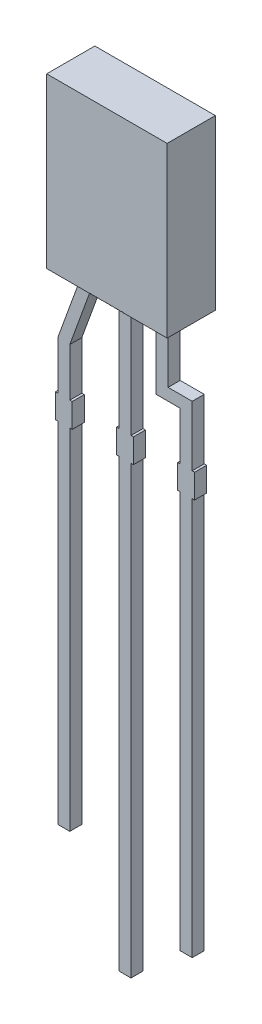
from build123d import *

# Parameters (mm, degrees)
EXTRUDE1_DEPTH     = 1
EXTRUDE2_DEPTH     = 0.25
SKETCH4_W          = 0.025316456
SKETCH4_H          = 0.026582278
CUT_EXTRUDE1_DEPTH = 0.01


with BuildPart() as part:
    # Sketch3 → Extrude1 (new body, symmetric)
    with BuildSketch(Plane(origin=(0, 0, 0), x_dir=(-1, 0, 0), z_dir=(0, 0, -1))):
        Polygon((-2.5, 0), (-1.79, 0), (-1.29, 0), (-0.25, 0), (0.25, 0), (1.198089297, 0), (1.698089297, 0), (2.5, 0), (2.5, 7), (-2.5, 7), align=None)
    extrude(amount=EXTRUDE1_DEPTH, both=True)

    # Sketch3_4 → Extrude2 (add, symmetric)
    with BuildSketch(Plane(origin=(0, 0, 0), x_dir=(-1, 0, 0), z_dir=(0, 0, -1))):
        Polygon((-1.29, 0), (-1.79, 0), (-1.79, -2.5), (-2.79, -2.5), (-2.79, -5), (-2.89, -5), (-2.89, -6), (-2.79, -6), (-2.79, -22.5), (-2.29, -22.5), (-2.29, -6), (-2.19, -6), (-2.19, -5), (-2.29, -5), (-2.29, -3), (-1.29, -3), align=None)
        Polygon((0.25, 0), (-0.25, 0), (-0.25, -5), (-0.35, -5), (-0.35, -6), (-0.25, -6), (-0.25, -24.5), (0.25, -24.5), (0.25, -6), (0.35, -6), (0.35, -5), (0.25, -5), align=None)
        Polygon((1.698089297, 0), (1.198089297, 0), (2.29, -3), (2.29, -5), (2.19, -5), (2.19, -6), (2.29, -6), (2.29, -20.5), (2.79, -20.5), (2.79, -6), (2.89, -6), (2.89, -5), (2.79, -5), (2.79, -3), align=None)
    extrude(amount=EXTRUDE2_DEPTH, both=True)

    # Sketch4 → Cut-Extrude1 (cut)
    with BuildSketch(Plane.XZ):
        Polygon((0.572151899, 0.925316456), (0.595609177, 1), (0.620352057, 1), (0.636768196, 0.949663766), (0.652294304, 1), (0.678026108, 1), (0.701265823, 0.925316456), (0.676087816, 0.925316456), (0.663093354, 0.976799842), (0.646677215, 0.925316456), (0.625178006, 0.925316456), (0.608860759, 0.976799842), (0.596044304, 0.925316456), align=None)
        Polygon((0.437974684, 0.925316456), (0.461431962, 1), (0.486174842, 1), (0.502590981, 0.949663766), (0.518117089, 1), (0.543848892, 1), (0.567088608, 0.925316456), (0.541910601, 0.925316456), (0.528916139, 0.976799842), (0.5125, 0.925316456), (0.491000791, 0.925316456), (0.474683544, 0.976799842), (0.461867089, 0.925316456), align=None)
        Polygon((0.303797468, 0.925316456), (0.327254747, 1), (0.351997627, 1), (0.368413766, 0.949663766), (0.383939873, 1), (0.409671677, 1), (0.432911392, 0.925316456), (0.407733386, 0.925316456), (0.394738924, 0.976799842), (0.378322785, 0.925316456), (0.356823576, 0.925316456), (0.340506329, 0.976799842), (0.327689873, 0.925316456), align=None)
        with Locations((0.275949367, 0.986708861)):
            Rectangle(SKETCH4_W, SKETCH4_H)
        with BuildLine():
            add(Edge.make_bspline(
                [(0.159493671, 0.968829114), (0.159530199, 0.970051228), (0.159601928, 0.972451052), (0.16021109, 0.975959018), (0.161206614, 0.979282301), (0.162570953, 0.982445017), (0.164384941, 0.985400383), (0.166539954, 0.98821895), (0.169151869, 0.990802912), (0.172088905, 0.993241673), (0.175386832, 0.995424068), (0.178989454, 0.997324206), (0.182859774, 0.998948925), (0.187013794, 1.000280615), (0.191459372, 1.001271382), (0.196177149, 1.001994699), (0.201170497, 1.002468207), (0.204594085, 1.002510148), (0.206348892, 1.002531646)],
                knots=[0, 0, 0, 0, 0.907421153, 1.781872267, 2.635683434, 3.480115191, 4.332689235, 5.205575272, 6.109500117, 7.055808355, 8.037942167, 9.041423561, 10.07750834, 11.152467461, 12.277657752, 13.45734338, 14.696726425, 16, 16, 16, 16], degree=3))
            add(Edge.make_bspline(
                [(0.206348892, 1.002531646), (0.208366877, 1.002504381), (0.212275063, 1.002451577), (0.217942631, 1.002066204), (0.223206098, 1.001378254), (0.228103845, 1.000421674), (0.232708145, 0.999218389), (0.23714149, 0.997927745), (0.241422782, 0.996463164), (0.244195874, 0.995363028), (0.24556962, 0.994818038)],
                knots=[0, 0, 0, 0, 1.203182053, 2.33017619, 3.384818652, 4.366208123, 5.30340534, 6.221361684, 7.118890722, 8, 8, 8, 8], degree=3))
            Line((0.24556962, 0.994818038), (0.24556962, 0.970886076))
            Line((0.24556962, 0.970886076), (0.242721519, 0.970886076))
            add(Edge.make_bspline(
                [(0.242721519, 0.970886076), (0.241355956, 0.971967039), (0.238632846, 0.974122618), (0.234205888, 0.976890972), (0.229546876, 0.979263982), (0.224708482, 0.981246605), (0.219807114, 0.982822219), (0.214938046, 0.983949125), (0.210169064, 0.984688489), (0.207010742, 0.98477005), (0.205458861, 0.984810127)],
                knots=[0, 0, 0, 0, 1.030738938, 2.055426519, 3.085610749, 4.123842265, 5.148648843, 6.130724483, 7.081507926, 8, 8, 8, 8], degree=3))
            add(Edge.make_bspline(
                [(0.205458861, 0.984810127), (0.205030115, 0.984808826), (0.204112202, 0.984806041), (0.202643054, 0.984684726), (0.200986711, 0.984556882), (0.199205972, 0.984360768), (0.197418768, 0.984129623), (0.19575852, 0.983783156), (0.194257758, 0.983414005), (0.193351089, 0.983046739), (0.192919304, 0.982871835)],
                knots=[0, 0, 0, 0, 0.806537132, 1.726733348, 2.77251655, 3.932999672, 5.098049949, 6.161349231, 7.124375527, 8, 8, 8, 8], degree=3))
            add(Edge.make_bspline(
                [(0.192919304, 0.982871835), (0.192439817, 0.9826436), (0.191497525, 0.982195068), (0.190194994, 0.981381158), (0.189024509, 0.980486413), (0.187963807, 0.97952468), (0.187101412, 0.978361692), (0.186480251, 0.976962421), (0.18613568, 0.975313128), (0.186096608, 0.974137966), (0.186075949, 0.973516614)],
                knots=[0, 0, 0, 0, 1.02474257, 2.013837243, 2.958431669, 3.867978675, 4.769292696, 5.732237074, 6.800947934, 8, 8, 8, 8], degree=3))
            add(Edge.make_bspline(
                [(0.186075949, 0.973516614), (0.186107411, 0.972970748), (0.186169273, 0.971897414), (0.186750779, 0.970368984), (0.187634826, 0.968948848), (0.188914241, 0.967683512), (0.190527919, 0.9665574), (0.192458907, 0.965546637), (0.194732757, 0.964710879), (0.19636997, 0.964273007), (0.197231013, 0.964042722)],
                knots=[0, 0, 0, 0, 0.825427492, 1.623033598, 2.45033906, 3.348940377, 4.33183287, 5.428402891, 6.647546779, 8, 8, 8, 8], degree=3))
            add(Edge.make_bspline(
                [(0.197231013, 0.964042722), (0.199200253, 0.963597517), (0.203235465, 0.962685239), (0.209375278, 0.961497785), (0.215513981, 0.960271914), (0.219470238, 0.959057599), (0.221400316, 0.95846519)],
                knots=[0, 0, 0, 0, 0.976118991, 2.000185432, 3.024380873, 4, 4, 4, 4], degree=3))
            add(Edge.make_bspline(
                [(0.221400316, 0.95846519), (0.222438469, 0.958111467), (0.224459331, 0.957422913), (0.227358523, 0.956270264), (0.230001771, 0.95496513), (0.23245931, 0.953643092), (0.234651974, 0.952163034), (0.236646608, 0.950630275), (0.238399268, 0.94897747), (0.239925706, 0.947227978), (0.241268572, 0.945391616), (0.242421982, 0.943444475), (0.243383004, 0.941378025), (0.244206396, 0.939222628), (0.244817623, 0.936948093), (0.245240059, 0.934571676), (0.245538122, 0.932088189), (0.245558978, 0.930393854), (0.24556962, 0.929529272)],
                knots=[0, 0, 0, 0, 1.287376879, 2.505999703, 3.65855109, 4.746193839, 5.778582289, 6.760029101, 7.696159662, 8.601061861, 9.48181646, 10.363080883, 11.252765705, 12.153987336, 13.068239035, 14.012364187, 14.985753787, 16, 16, 16, 16], degree=3))
            add(Edge.make_bspline(
                [(0.24556962, 0.929529272), (0.24553232, 0.928373126), (0.245458913, 0.926097851), (0.244857463, 0.922768828), (0.243830953, 0.91962001), (0.242444593, 0.916616854), (0.2406171, 0.91380259), (0.238424977, 0.911125104), (0.235814667, 0.908632608), (0.23282934, 0.906333971), (0.229542493, 0.904255166), (0.226008488, 0.902418458), (0.222229636, 0.900912011), (0.218249751, 0.89963078), (0.214030359, 0.898678384), (0.209593388, 0.897958807), (0.204919526, 0.897545806), (0.201728115, 0.897494531), (0.200098892, 0.897468354)],
                knots=[0, 0, 0, 0, 0.894901293, 1.761149761, 2.608783409, 3.453876344, 4.314933854, 5.200038827, 6.12799933, 7.103249695, 8.113098521, 9.136064399, 10.182719798, 11.259667356, 12.370545059, 13.528828137, 14.738461593, 16, 16, 16, 16], degree=3))
            add(Edge.make_bspline(
                [(0.200098892, 0.897468354), (0.198430241, 0.897490747), (0.195095767, 0.897535495), (0.190113794, 0.897910464), (0.185156379, 0.898476966), (0.180284815, 0.89927642), (0.175602308, 0.900294076), (0.171185694, 0.901380034), (0.167106724, 0.902620424), (0.164532999, 0.903574469), (0.163291139, 0.90403481)],
                knots=[0, 0, 0, 0, 1.065379838, 2.128953261, 3.188461447, 4.250817766, 5.279613205, 6.247547721, 7.154416075, 8, 8, 8, 8], degree=3))
            Line((0.163291139, 0.90403481), (0.163291139, 0.926582278))
            Line((0.163291139, 0.926582278), (0.166119462, 0.926582278))
            add(Edge.make_bspline(
                [(0.166119462, 0.926582278), (0.167192422, 0.925782075), (0.169386652, 0.924145637), (0.173045405, 0.92205966), (0.177009465, 0.920110146), (0.181274367, 0.918388353), (0.185746907, 0.916967752), (0.190324453, 0.915938708), (0.194951518, 0.915299585), (0.198053109, 0.915226452), (0.19960443, 0.915189873)],
                knots=[0, 0, 0, 0, 0.89224925, 1.824673196, 2.804309561, 3.838364047, 4.890042674, 5.931526337, 6.965412421, 8, 8, 8, 8], degree=3))
            add(Edge.make_bspline(
                [(0.19960443, 0.915189873), (0.20069973, 0.915214083), (0.202889476, 0.915262484), (0.206163883, 0.915611738), (0.209398675, 0.916283479), (0.211441573, 0.917097816), (0.212460443, 0.917503956)],
                knots=[0, 0, 0, 0, 0.998993879, 1.997209027, 3.00113285, 4, 4, 4, 4], degree=3))
            add(Edge.make_bspline(
                [(0.212460443, 0.917503956), (0.212893922, 0.917705438), (0.213760592, 0.91810827), (0.214967595, 0.918880595), (0.216070899, 0.919810313), (0.217071904, 0.920862707), (0.21791996, 0.922032042), (0.21855762, 0.923301801), (0.218918439, 0.92466378), (0.218964276, 0.925597948), (0.218987342, 0.926068038)],
                knots=[0, 0, 0, 0, 1.005454979, 2.010239304, 3.005296729, 4.036100111, 5.060531193, 6.034954812, 7.011155677, 8, 8, 8, 8], degree=3))
            add(Edge.make_bspline(
                [(0.218987342, 0.926068038), (0.218952547, 0.926705969), (0.218886059, 0.927924997), (0.218286061, 0.929638693), (0.217288392, 0.931101805), (0.216135293, 0.932094798), (0.215018314, 0.932793558), (0.213977797, 0.933298798), (0.212778346, 0.933812221), (0.211400897, 0.934301418), (0.209865762, 0.934795464), (0.20815684, 0.935270134), (0.206274232, 0.935719693), (0.204958342, 0.936005845), (0.204272152, 0.936155063)],
                knots=[0, 0, 0, 0, 1.174343879, 2.244064321, 3.303704314, 4.407076671, 5.02483983, 5.732197225, 6.53898402, 7.431906431, 8.428480183, 9.514816237, 10.704066255, 12, 12, 12, 12], degree=3))
            add(Edge.make_bspline(
                [(0.204272152, 0.936155063), (0.202439527, 0.936531783), (0.198838824, 0.937271955), (0.193433749, 0.938366252), (0.187940695, 0.939678769), (0.184270145, 0.940807982), (0.182357595, 0.941396361)],
                knots=[0, 0, 0, 0, 0.995788186, 1.956503735, 2.935230479, 4, 4, 4, 4], degree=3))
            add(Edge.make_bspline(
                [(0.182357595, 0.941396361), (0.181411038, 0.941715602), (0.179559421, 0.94234009), (0.176918823, 0.943426408), (0.17447165, 0.944600265), (0.172205016, 0.945842235), (0.17012965, 0.947184668), (0.16824336, 0.948610001), (0.166545403, 0.950114784), (0.165056655, 0.951730504), (0.163727897, 0.953440852), (0.162615553, 0.955291465), (0.161619968, 0.957234994), (0.160866813, 0.959328437), (0.160242304, 0.961526965), (0.159820561, 0.963858899), (0.159526198, 0.966303117), (0.159504634, 0.967977716), (0.159493671, 0.968829114)],
                knots=[0, 0, 0, 0, 1.237326419, 2.420410185, 3.534642089, 4.598489486, 5.620241961, 6.59385002, 7.525152549, 8.426792174, 9.312230456, 10.203151844, 11.098070343, 12.012931196, 12.954244379, 13.926618287, 14.945853925, 16, 16, 16, 16], degree=3))
        make_face()
        with BuildLine():
            Line((0.067088608, 1), (0.091139241, 1))
            Line((0.091139241, 1), (0.091139241, 0.992167722))
            add(Edge.make_bspline(
                [(0.091139241, 0.992167722), (0.092232434, 0.992976516), (0.094340096, 0.994535861), (0.097514655, 0.996612923), (0.100532955, 0.998397345), (0.103463307, 0.999920462), (0.106469584, 1.001132633), (0.109707718, 1.001951014), (0.113209314, 1.002453738), (0.115636384, 1.002505099), (0.116890823, 1.002531646)],
                knots=[0, 0, 0, 0, 1.150945962, 2.219006967, 3.209666795, 4.118194914, 5.012574058, 5.946577101, 6.93868214, 8, 8, 8, 8], degree=3))
            add(Edge.make_bspline(
                [(0.116890823, 1.002531646), (0.117907098, 1.002508698), (0.119886079, 1.002464012), (0.122764378, 1.002122291), (0.125466344, 1.001573882), (0.127995181, 1.000805475), (0.130344881, 0.999802444), (0.132488561, 0.99853081), (0.134491138, 0.997098096), (0.136273085, 0.99539173), (0.137888631, 0.993493812), (0.139271202, 0.991361403), (0.140448907, 0.989028463), (0.141390007, 0.986476613), (0.142145096, 0.983718309), (0.142669028, 0.980739061), (0.142989621, 0.977551934), (0.14302156, 0.975356803), (0.143037975, 0.974228639)],
                knots=[0, 0, 0, 0, 1.108959949, 2.159465255, 3.158589008, 4.114545495, 5.039534357, 5.93921201, 6.830099133, 7.720870013, 8.624681761, 9.544731627, 10.487599671, 11.471264588, 12.508152322, 13.604835107, 14.769030043, 16, 16, 16, 16], degree=3))
            Line((0.143037975, 0.974228639), (0.143037975, 0.925316456))
            Line((0.143037975, 0.925316456), (0.118987342, 0.925316456))
            Line((0.118987342, 0.925316456), (0.118987342, 0.96289557))
            add(Edge.make_bspline(
                [(0.118987342, 0.96289557), (0.118985706, 0.963812041), (0.118982576, 0.965566256), (0.118900237, 0.968072063), (0.118779336, 0.970340235), (0.118640631, 0.972382264), (0.118387615, 0.974229015), (0.118009906, 0.975895176), (0.11753908, 0.977414778), (0.117074761, 0.978321479), (0.116851266, 0.978757911)],
                knots=[0, 0, 0, 0, 1.361401701, 2.605856924, 3.723918663, 4.735739235, 5.645738665, 6.489217889, 7.27279937, 8, 8, 8, 8], degree=3))
            add(Edge.make_bspline(
                [(0.116851266, 0.978757911), (0.116621257, 0.979156617), (0.11616908, 0.979940438), (0.115248816, 0.98094675), (0.114169974, 0.9817905), (0.11289277, 0.982448601), (0.111403203, 0.982939104), (0.109682344, 0.983319675), (0.107690603, 0.983491553), (0.106283135, 0.983526043), (0.105537975, 0.983544304)],
                knots=[0, 0, 0, 0, 0.849004071, 1.669068917, 2.503060811, 3.370079215, 4.310762265, 5.396376419, 6.621555549, 8, 8, 8, 8], degree=3))
            add(Edge.make_bspline(
                [(0.105537975, 0.983544304), (0.104997032, 0.983524465), (0.103885616, 0.983483703), (0.102168163, 0.983292162), (0.100378903, 0.982893004), (0.097860234, 0.982248059), (0.094695025, 0.981054204), (0.09233549, 0.979701058), (0.091139241, 0.979015032)],
                knots=[0, 0, 0, 0, 0.638062719, 1.310959128, 2.033463623, 2.796942592, 4.376095945, 6, 6, 6, 6], degree=3))
            Line((0.091139241, 0.979015032), (0.091139241, 0.925316456))
            Line((0.091139241, 0.925316456), (0.067088608, 0.925316456))
            Line((0.067088608, 0.925316456), (0.067088608, 1))
        make_face()
        with BuildLine():
            Line((-0.030379747, 1), (-0.006329114, 1))
            Line((-0.006329114, 1), (-0.006329114, 0.962420886))
            add(Edge.make_bspline(
                [(-0.006329114, 0.962420886), (-0.006304108, 0.960890897), (-0.006254136, 0.957833405), (-0.005977585, 0.954070311), (-0.005593098, 0.951228771), (-0.005225559, 0.949397183), (-0.004793687, 0.947849066), (-0.004381426, 0.946963305), (-0.004193038, 0.946558544)],
                knots=[0, 0, 0, 0, 1.709111167, 3.415443484, 4.21113913, 4.910175115, 5.501990373, 6, 6, 6, 6], degree=3))
            add(Edge.make_bspline(
                [(-0.004193038, 0.946558544), (-0.003948577, 0.946160481), (-0.003469277, 0.945380023), (-0.002531926, 0.944367147), (-0.001438143, 0.943537778), (-0.000166967, 0.942858311), (0.001321142, 0.942379123), (0.003045059, 0.942026369), (0.005025244, 0.941815815), (0.006434073, 0.941787262), (0.007179589, 0.941772152)],
                knots=[0, 0, 0, 0, 0.860202684, 1.686548532, 2.528236983, 3.382486038, 4.33249885, 5.401154041, 6.624757403, 8, 8, 8, 8], degree=3))
            add(Edge.make_bspline(
                [(0.007179589, 0.941772152), (0.008310478, 0.941832252), (0.010618173, 0.941954894), (0.013493483, 0.94262156), (0.015810821, 0.943481524), (0.017668538, 0.94423196), (0.01957626, 0.945206061), (0.020855802, 0.945927502), (0.021518987, 0.946301424)],
                knots=[0, 0, 0, 0, 1.33818541, 2.730705359, 3.468371228, 4.262126284, 5.099261778, 6, 6, 6, 6], degree=3))
            Line((0.021518987, 0.946301424), (0.021518987, 1))
            Line((0.021518987, 1), (0.04556962, 1))
            Line((0.04556962, 1), (0.04556962, 0.925316456))
            Line((0.04556962, 0.925316456), (0.021518987, 0.925316456))
            Line((0.021518987, 0.925316456), (0.021518987, 0.933148734))
            add(Edge.make_bspline(
                [(0.021518987, 0.933148734), (0.020461581, 0.932342583), (0.018403276, 0.93077336), (0.015224038, 0.92873294), (0.01214014, 0.926934171), (0.009087131, 0.925421354), (0.005972176, 0.924214579), (0.002709417, 0.92340359), (-0.000706989, 0.922859787), (-0.003043704, 0.922810094), (-0.004232595, 0.92278481)],
                knots=[0, 0, 0, 0, 1.126119141, 2.192057864, 3.198061997, 4.149848529, 5.076251285, 6.021887753, 6.99356175, 8, 8, 8, 8], degree=3))
            add(Edge.make_bspline(
                [(-0.004232595, 0.92278481), (-0.00522886, 0.92281021), (-0.007173746, 0.922859797), (-0.010008596, 0.923169348), (-0.012679702, 0.923720571), (-0.015173087, 0.924516428), (-0.017508773, 0.925507787), (-0.019682445, 0.926711766), (-0.021668294, 0.928175048), (-0.023496446, 0.929834986), (-0.025135546, 0.931726284), (-0.026532456, 0.933855662), (-0.027736818, 0.936192582), (-0.028686083, 0.938755219), (-0.029477407, 0.941521491), (-0.02998217, 0.944520121), (-0.030339823, 0.947730007), (-0.030366173, 0.949946157), (-0.030379747, 0.951087816)],
                knots=[0, 0, 0, 0, 1.08828964, 2.12453497, 3.110382522, 4.062402335, 4.978696626, 5.878225494, 6.769849763, 7.667011675, 8.57076823, 9.495541561, 10.442454184, 11.436213583, 12.475881554, 13.580560132, 14.753614518, 16, 16, 16, 16], degree=3))
            Line((-0.030379747, 0.951087816), (-0.030379747, 1))
        make_face()
        Polygon((-0.125316456, 1), (-0.053164557, 1), (-0.053164557, 0.9), (-0.078481013, 0.9), (-0.078481013, 0.981012658), (-0.125316456, 0.981012658), align=None)
        Polygon((-0.212658228, 1), (-0.140506329, 1), (-0.140506329, 0.9), (-0.212658228, 0.9), (-0.212658228, 0.918987342), (-0.165822785, 0.918987342), (-0.165822785, 0.936708861), (-0.208860759, 0.936708861), (-0.208860759, 0.955696203), (-0.165822785, 0.955696203), (-0.165822785, 0.981012658), (-0.212658228, 0.981012658), align=None)
        with BuildLine():
            add(Edge.make_bspline(
                [(-0.329113924, 0.950098892), (-0.329094609, 0.951246581), (-0.329056357, 0.953519467), (-0.328761165, 0.956884274), (-0.32823514, 0.960149949), (-0.327555959, 0.963334198), (-0.326633453, 0.966413126), (-0.325551739, 0.969420703), (-0.324242093, 0.972326196), (-0.322737241, 0.975127631), (-0.321087768, 0.977799734), (-0.319313019, 0.980319942), (-0.31746724, 0.98270316), (-0.315477927, 0.984898054), (-0.313398746, 0.986940074), (-0.311223217, 0.988830888), (-0.308918153, 0.990534319), (-0.30731099, 0.991557203), (-0.30650712, 0.992068829)],
                knots=[0, 0, 0, 0, 1.105570398, 2.18947457, 3.250358341, 4.290584537, 5.323553275, 6.344225964, 7.367641686, 8.3905646, 9.405808457, 10.390761353, 11.358902336, 12.307789878, 13.241960776, 14.165076779, 15.082208636, 16, 16, 16, 16], degree=3))
            add(Edge.make_bspline(
                [(-0.30650712, 0.992068829), (-0.305267933, 0.99278115), (-0.302783236, 0.994209427), (-0.298798778, 0.995875266), (-0.294677169, 0.997289489), (-0.290317988, 0.99830293), (-0.285679267, 0.999072765), (-0.280674456, 0.999620936), (-0.27526755, 0.999926439), (-0.271532557, 0.999974921), (-0.269600475, 1)],
                knots=[0, 0, 0, 0, 0.896321744, 1.797216976, 2.705381885, 3.628777036, 4.602292017, 5.655629376, 6.787275635, 8, 8, 8, 8], degree=3))
            Line((-0.269600475, 1), (-0.234177215, 1))
            Line((-0.234177215, 1), (-0.234177215, 0.9))
            Line((-0.234177215, 0.9), (-0.270609177, 0.9))
            add(Edge.make_bspline(
                [(-0.270609177, 0.9), (-0.272587873, 0.90001681), (-0.276404533, 0.900049235), (-0.281921849, 0.900464162), (-0.287024188, 0.901069925), (-0.291713768, 0.901964111), (-0.296016217, 0.903078692), (-0.299933509, 0.904467223), (-0.303549742, 0.90595984), (-0.305728277, 0.907234394), (-0.306784019, 0.907852057)],
                knots=[0, 0, 0, 0, 1.267083275, 2.444046388, 3.541868212, 4.55639609, 5.499737919, 6.385160515, 7.217431253, 8, 8, 8, 8], degree=3))
            add(Edge.make_bspline(
                [(-0.306784019, 0.907852057), (-0.307634972, 0.908388598), (-0.309327097, 0.909455511), (-0.311728312, 0.911237363), (-0.313957739, 0.91319344), (-0.316086242, 0.915245259), (-0.318066059, 0.917448146), (-0.319909259, 0.919786853), (-0.321613076, 0.922264947), (-0.323171039, 0.924874416), (-0.324591854, 0.927604468), (-0.32578116, 0.930477527), (-0.326830509, 0.933456057), (-0.327636046, 0.936565019), (-0.32833396, 0.939772856), (-0.328768694, 0.9431142), (-0.329055305, 0.946566688), (-0.32909422, 0.948911578), (-0.329113924, 0.950098892)],
                knots=[0, 0, 0, 0, 0.964065863, 1.917049184, 2.86229036, 3.805247319, 4.749389377, 5.698846072, 6.657678277, 7.629829384, 8.610569287, 9.604676042, 10.607940105, 11.6349849, 12.681042988, 13.752616828, 14.862056989, 16, 16, 16, 16], degree=3))
        make_face()
        with BuildLine():
            add(Edge.make_bspline(
                [(-0.302531646, 0.949940665), (-0.302488343, 0.948362234), (-0.30240473, 0.945314435), (-0.301699336, 0.940918791), (-0.300560086, 0.936875841), (-0.299222393, 0.933763425), (-0.297885002, 0.931490107), (-0.296757478, 0.929891837), (-0.295507812, 0.928377637), (-0.294117203, 0.926968797), (-0.292582019, 0.925661761), (-0.29092076, 0.92443285), (-0.289120719, 0.923304205), (-0.287847688, 0.922644199), (-0.287203323, 0.922310127)],
                knots=[0, 0, 0, 0, 1.694683197, 3.272273219, 4.767406206, 6.197615014, 6.895990032, 7.597410435, 8.296503208, 9.002591366, 9.720792421, 10.460154445, 11.220583224, 12, 12, 12, 12], degree=3))
            add(Edge.make_bspline(
                [(-0.287203323, 0.922310127), (-0.286528388, 0.922003612), (-0.285190619, 0.921396079), (-0.283120344, 0.920661993), (-0.281027643, 0.920099666), (-0.278833415, 0.919627243), (-0.276356655, 0.919350107), (-0.273434164, 0.919137431), (-0.269977491, 0.919000503), (-0.267490895, 0.918991932), (-0.266159019, 0.918987342)],
                knots=[0, 0, 0, 0, 0.826913061, 1.638999358, 2.447478739, 3.243919028, 4.140906711, 5.225381046, 6.513851968, 8, 8, 8, 8], degree=3))
            Line((-0.266159019, 0.918987342), (-0.259493671, 0.918987342))
            Line((-0.259493671, 0.918987342), (-0.259493671, 0.981012658))
            Line((-0.259493671, 0.981012658), (-0.266159019, 0.981012658))
            add(Edge.make_bspline(
                [(-0.266159019, 0.981012658), (-0.26691721, 0.981007613), (-0.268380945, 0.980997872), (-0.270497399, 0.980958769), (-0.272462161, 0.980898452), (-0.274269511, 0.98082661), (-0.275925648, 0.980711707), (-0.277413482, 0.98054311), (-0.278755832, 0.980398723), (-0.280323467, 0.980131603), (-0.282176615, 0.979715148), (-0.284337881, 0.979037056), (-0.286478414, 0.978186637), (-0.287866987, 0.977501673), (-0.288568038, 0.977155854)],
                knots=[0, 0, 0, 0, 1.186775798, 2.291144404, 3.313233901, 4.263515562, 5.122260739, 5.910868134, 6.60717912, 7.234883681, 8.398964994, 9.577230746, 10.776813768, 12, 12, 12, 12], degree=3))
            add(Edge.make_bspline(
                [(-0.288568038, 0.977155854), (-0.289151752, 0.976812378), (-0.290299689, 0.976136894), (-0.291943833, 0.975031032), (-0.293430573, 0.973796032), (-0.294836635, 0.972512934), (-0.296089501, 0.97112248), (-0.297262794, 0.969672), (-0.29827305, 0.968109607), (-0.299518045, 0.965916078), (-0.300737777, 0.962882708), (-0.301778537, 0.958916165), (-0.302415052, 0.954556155), (-0.302491785, 0.951518573), (-0.302531646, 0.949940665)],
                knots=[0, 0, 0, 0, 0.755109416, 1.485004392, 2.205961541, 2.908125208, 3.605307969, 4.290649036, 4.985852759, 5.676964147, 7.100721462, 8.614478074, 10.241350405, 12, 12, 12, 12], degree=3))
        make_face(mode=Mode.SUBTRACT)
        with Locations((-0.360759494, 0.986708861)):
            Rectangle(SKETCH4_W, SKETCH4_H)
        with BuildLine():
            add(Edge.make_bspline(
                [(-0.435403481, 1.002531646), (-0.433813375, 1.002509819), (-0.430692253, 1.002466978), (-0.426120809, 1.001990276), (-0.421756006, 1.001271809), (-0.417608387, 1.000253637), (-0.413701826, 0.998897295), (-0.410020773, 0.99727928), (-0.406631411, 0.995261474), (-0.404567681, 0.993684533), (-0.403540348, 0.992899525)],
                knots=[0, 0, 0, 0, 1.123606455, 2.205459211, 3.245124445, 4.248821949, 5.220056174, 6.165006393, 7.086533249, 8, 8, 8, 8], degree=3))
            add(Edge.make_bspline(
                [(-0.403540348, 0.992899525), (-0.402588601, 0.992044751), (-0.400688786, 0.990338508), (-0.398222853, 0.987367081), (-0.396099767, 0.984084037), (-0.394314215, 0.980481815), (-0.392883291, 0.976565086), (-0.391860157, 0.972320424), (-0.391240912, 0.967759643), (-0.391173746, 0.96461171), (-0.391139241, 0.962994462)],
                knots=[0, 0, 0, 0, 0.916457077, 1.82937027, 2.759194969, 3.714948755, 4.706655623, 5.743329475, 6.840637961, 8, 8, 8, 8], degree=3))
            add(Edge.make_bspline(
                [(-0.391139241, 0.962994462), (-0.391178001, 0.961291235), (-0.391253124, 0.957990155), (-0.391916883, 0.953217967), (-0.392986496, 0.948800287), (-0.394524054, 0.944748378), (-0.396454496, 0.941055187), (-0.398718989, 0.937683352), (-0.401339514, 0.934640428), (-0.403346653, 0.932894988), (-0.404351266, 0.932021361)],
                knots=[0, 0, 0, 0, 1.171797512, 2.271099083, 3.308930235, 4.294129479, 5.24602549, 6.17106565, 7.084581485, 8, 8, 8, 8], degree=3))
            add(Edge.make_bspline(
                [(-0.404351266, 0.932021361), (-0.405377179, 0.931252899), (-0.407441398, 0.929706695), (-0.410844242, 0.927804084), (-0.414471932, 0.92621589), (-0.418293668, 0.924939171), (-0.422268653, 0.923984554), (-0.426332207, 0.923291888), (-0.430476009, 0.922863206), (-0.433266389, 0.922811068), (-0.434671677, 0.92278481)],
                knots=[0, 0, 0, 0, 0.952046378, 1.915591786, 2.889970712, 3.892742799, 4.906722985, 5.925995921, 6.955492795, 8, 8, 8, 8], degree=3))
            add(Edge.make_bspline(
                [(-0.434671677, 0.92278481), (-0.435918482, 0.922801208), (-0.438370122, 0.922833451), (-0.441968962, 0.923164054), (-0.44542692, 0.923665992), (-0.448733839, 0.924404564), (-0.451900836, 0.925326181), (-0.454954975, 0.926358243), (-0.457914207, 0.927493474), (-0.459814852, 0.928377751), (-0.460759494, 0.928817247)],
                knots=[0, 0, 0, 0, 1.107549047, 2.177816721, 3.208424937, 4.210433793, 5.185680559, 6.13785309, 7.074491882, 8, 8, 8, 8], degree=3))
            Line((-0.460759494, 0.928817247), (-0.460759494, 0.949367089))
            Line((-0.460759494, 0.949367089), (-0.45741693, 0.949367089))
            add(Edge.make_bspline(
                [(-0.45741693, 0.949367089), (-0.456916353, 0.948951202), (-0.455831328, 0.94804975), (-0.454064496, 0.946603162), (-0.451894176, 0.945102872), (-0.450247147, 0.944208247), (-0.449367089, 0.943730222)],
                knots=[0, 0, 0, 0, 0.792743043, 1.718305972, 2.780820752, 4, 4, 4, 4], degree=3))
            add(Edge.make_bspline(
                [(-0.449367089, 0.943730222), (-0.448438153, 0.943291583), (-0.446532244, 0.942391623), (-0.443989036, 0.941514235), (-0.441785857, 0.940988866), (-0.439972197, 0.940723301), (-0.4380379, 0.940536442), (-0.436702754, 0.940516551), (-0.436016614, 0.940506329)],
                knots=[0, 0, 0, 0, 1.332360773, 2.733622135, 3.480580446, 4.268165618, 5.10999921, 6, 6, 6, 6], degree=3))
            add(Edge.make_bspline(
                [(-0.436016614, 0.940506329), (-0.435250975, 0.94052566), (-0.433767202, 0.940563122), (-0.431606835, 0.94084317), (-0.429582217, 0.941311262), (-0.427694179, 0.941989206), (-0.425940348, 0.942840972), (-0.424320324, 0.943882418), (-0.422826892, 0.945105689), (-0.421507951, 0.946547321), (-0.420315137, 0.948127061), (-0.41929596, 0.949861229), (-0.418383497, 0.951707813), (-0.41768856, 0.953712266), (-0.417128822, 0.955841041), (-0.416739892, 0.958104161), (-0.416497934, 0.960503671), (-0.416470016, 0.962149979), (-0.416455696, 0.962994462)],
                knots=[0, 0, 0, 0, 1.087372478, 2.107277257, 3.088614887, 4.033572876, 4.950837204, 5.852283781, 6.763600506, 7.684681617, 8.621202104, 9.570420019, 10.537986648, 11.542161979, 12.577980734, 13.661919757, 14.800668594, 16, 16, 16, 16], degree=3))
            add(Edge.make_bspline(
                [(-0.416455696, 0.962994462), (-0.416470471, 0.963858618), (-0.416499177, 0.965537631), (-0.416732691, 0.967979242), (-0.417148582, 0.970260673), (-0.41771983, 0.972385993), (-0.418444178, 0.974352011), (-0.419349295, 0.976149408), (-0.420385652, 0.977806215), (-0.42163021, 0.979268827), (-0.422994093, 0.980585149), (-0.424508985, 0.981721283), (-0.426168224, 0.982669428), (-0.427950405, 0.983473891), (-0.429883445, 0.984052289), (-0.431939982, 0.984488981), (-0.434129537, 0.984777538), (-0.435639891, 0.984799101), (-0.436412184, 0.984810127)],
                knots=[0, 0, 0, 0, 1.230336593, 2.390482092, 3.487897344, 4.52859895, 5.520747884, 6.465347575, 7.38981449, 8.296085817, 9.192433006, 10.084246191, 10.984321635, 11.908883871, 12.862027947, 13.850751296, 14.901019963, 16, 16, 16, 16], degree=3))
            add(Edge.make_bspline(
                [(-0.436412184, 0.984810127), (-0.437137949, 0.984801377), (-0.4385528, 0.98478432), (-0.4406198, 0.984574766), (-0.442577305, 0.984267994), (-0.444410447, 0.983828041), (-0.44611318, 0.98331549), (-0.447669514, 0.982742545), (-0.44908249, 0.982139419), (-0.44994378, 0.981671663), (-0.450356013, 0.981447785)],
                knots=[0, 0, 0, 0, 1.201052708, 2.34140671, 3.435973211, 4.479046096, 5.459661032, 6.378175262, 7.223757638, 8, 8, 8, 8], degree=3))
            add(Edge.make_bspline(
                [(-0.450356013, 0.981447785), (-0.451056218, 0.98101789), (-0.452410785, 0.980186248), (-0.454249513, 0.978784682), (-0.455894382, 0.977370422), (-0.456918894, 0.976414205), (-0.45741693, 0.975949367)],
                knots=[0, 0, 0, 0, 1.098601379, 2.125273733, 3.088655601, 4, 4, 4, 4], degree=3))
            Line((-0.45741693, 0.975949367), (-0.460759494, 0.975949367))
            Line((-0.460759494, 0.975949367), (-0.460759494, 0.996657437))
            add(Edge.make_bspline(
                [(-0.460759494, 0.996657437), (-0.459814104, 0.997094931), (-0.457923097, 0.997970024), (-0.455008518, 0.999123896), (-0.452020545, 1.000092057), (-0.448972172, 1.000995137), (-0.445800089, 1.001683499), (-0.442477058, 1.002176622), (-0.43899556, 1.002477534), (-0.436617171, 1.002513362), (-0.435403481, 1.002531646)],
                knots=[0, 0, 0, 0, 0.952012952, 1.904254716, 2.862729541, 3.822037426, 4.808956931, 5.82647221, 6.890850784, 8, 8, 8, 8], degree=3))
        make_face()
        with BuildLine():
            add(Edge.make_bspline(
                [(-0.553164557, 0.962697785), (-0.553139862, 0.964202691), (-0.553091723, 0.967136157), (-0.552552407, 0.971407948), (-0.551739627, 0.975443946), (-0.550567096, 0.979231154), (-0.549086703, 0.982788429), (-0.547235764, 0.986078221), (-0.545064759, 0.989131451), (-0.542573722, 0.991921336), (-0.53977252, 0.994419846), (-0.536698338, 0.996615099), (-0.533324511, 0.998428541), (-0.5297102, 0.999940631), (-0.525825548, 1.001109866), (-0.521671329, 1.001922584), (-0.517254195, 1.002458054), (-0.514215776, 1.002506706), (-0.512658228, 1.002531646)],
                knots=[0, 0, 0, 0, 1.120167703, 2.183507516, 3.201345984, 4.182878364, 5.131270247, 6.065524964, 6.98789854, 7.91635504, 8.84481154, 9.778033504, 10.722808862, 11.691211189, 12.691525459, 13.738229926, 14.840575679, 16, 16, 16, 16], degree=3))
            add(Edge.make_bspline(
                [(-0.512658228, 1.002531646), (-0.511100707, 1.002506624), (-0.508062341, 1.002457811), (-0.503644832, 1.00192348), (-0.499485737, 1.001105529), (-0.49559643, 0.999949428), (-0.491987684, 0.998422879), (-0.488617817, 0.996615831), (-0.485544052, 0.994419638), (-0.482742566, 0.991921446), (-0.480252248, 0.989131219), (-0.478078657, 0.986079037), (-0.476236243, 0.982783083), (-0.474718389, 0.979240037), (-0.473585065, 0.975439199), (-0.472761602, 0.971408758), (-0.472225394, 0.967135938), (-0.472176819, 0.964202617), (-0.472151899, 0.962697785)],
                knots=[0, 0, 0, 0, 1.15937715, 2.261678054, 3.308339936, 4.313313916, 5.277148057, 6.221884977, 7.155068972, 8.083487698, 9.011906424, 9.934242473, 10.868459181, 11.818729666, 12.798784262, 13.81658132, 14.879877871, 16, 16, 16, 16], degree=3))
            add(Edge.make_bspline(
                [(-0.472151899, 0.962697785), (-0.472177, 0.961186352), (-0.472226044, 0.958233324), (-0.472761711, 0.953934577), (-0.473578673, 0.949873481), (-0.474744205, 0.94606093), (-0.476250482, 0.942498454), (-0.478097428, 0.939192265), (-0.480293183, 0.936145491), (-0.482802618, 0.933355327), (-0.485615383, 0.930860799), (-0.488702882, 0.928682694), (-0.492066422, 0.926873901), (-0.495666774, 0.925346136), (-0.499554435, 0.92421359), (-0.503691062, 0.923395434), (-0.508088545, 0.922857525), (-0.511107271, 0.92280949), (-0.512658228, 0.92278481)],
                knots=[0, 0, 0, 0, 1.123883205, 2.195836198, 3.217400301, 4.202580581, 5.156396106, 6.089661422, 7.013912723, 7.944661364, 8.875797629, 9.805201257, 10.748976071, 11.711828658, 12.709674189, 13.755270167, 14.846705509, 16, 16, 16, 16], degree=3))
            add(Edge.make_bspline(
                [(-0.512658228, 0.92278481), (-0.514228966, 0.922809532), (-0.51728713, 0.922857665), (-0.521730542, 0.923393868), (-0.525904381, 0.924206873), (-0.529803006, 0.925373269), (-0.533428756, 0.926884682), (-0.536788831, 0.92871934), (-0.539860139, 0.930921398), (-0.542647393, 0.933428554), (-0.545127634, 0.936233956), (-0.54729655, 0.939283579), (-0.549103768, 0.942603295), (-0.550585538, 0.946158163), (-0.551757711, 0.949951933), (-0.552578696, 0.953986038), (-0.553084687, 0.958261035), (-0.553137471, 0.961193165), (-0.553164557, 0.962697785)],
                knots=[0, 0, 0, 0, 1.167358552, 2.272800965, 3.322628764, 4.326027541, 5.29287265, 6.238482395, 7.166210353, 8.096447471, 9.020151799, 9.945039072, 10.873038967, 11.824425184, 12.804379233, 13.820580988, 14.881633558, 16, 16, 16, 16], degree=3))
        make_face()
        with BuildLine():
            add(Edge.make_bspline(
                [(-0.523457278, 0.981190665), (-0.523812282, 0.980690583), (-0.524534755, 0.979672859), (-0.525410563, 0.977968205), (-0.526189141, 0.976135753), (-0.526809614, 0.974108125), (-0.527293459, 0.971813012), (-0.527601913, 0.969165457), (-0.527832257, 0.966130064), (-0.527842612, 0.963977333), (-0.527848101, 0.962836234)],
                knots=[0, 0, 0, 0, 0.765001119, 1.556867793, 2.387180485, 3.249178546, 4.200309879, 5.312433676, 6.575401142, 8, 8, 8, 8], degree=3))
            add(Edge.make_bspline(
                [(-0.527848101, 0.962836234), (-0.527830368, 0.96176136), (-0.527796392, 0.959702019), (-0.527610608, 0.956742154), (-0.527259147, 0.954052656), (-0.526765631, 0.951627948), (-0.526158041, 0.949455878), (-0.525423239, 0.94752355), (-0.524589801, 0.945809595), (-0.523904047, 0.944804474), (-0.523575949, 0.944323576)],
                knots=[0, 0, 0, 0, 1.337015307, 2.56157572, 3.686511827, 4.707709802, 5.636963675, 6.488272502, 7.276717686, 8, 8, 8, 8], degree=3))
            add(Edge.make_bspline(
                [(-0.523575949, 0.944323576), (-0.523238562, 0.943884486), (-0.522576697, 0.943023106), (-0.521401907, 0.941938218), (-0.520130386, 0.941047956), (-0.518765925, 0.940351973), (-0.517305736, 0.939870254), (-0.515803375, 0.939513765), (-0.514247193, 0.939288362), (-0.513192997, 0.939256612), (-0.512658228, 0.939240506)],
                knots=[0, 0, 0, 0, 1.058488312, 2.076474566, 3.046302828, 4.022760093, 4.996603884, 5.982315336, 6.976474174, 8, 8, 8, 8], degree=3))
            add(Edge.make_bspline(
                [(-0.512658228, 0.939240506), (-0.512130296, 0.939251453), (-0.511097679, 0.939272863), (-0.509595013, 0.939452545), (-0.508184065, 0.939747135), (-0.506844191, 0.940165068), (-0.505552217, 0.940760551), (-0.504317872, 0.941616975), (-0.503101936, 0.942692306), (-0.502363688, 0.943542825), (-0.501977848, 0.943987342)],
                knots=[0, 0, 0, 0, 1.041978199, 2.038073998, 2.982578265, 3.884042198, 4.804014415, 5.778706634, 6.839057036, 8, 8, 8, 8], degree=3))
            add(Edge.make_bspline(
                [(-0.501977848, 0.943987342), (-0.501644363, 0.944461968), (-0.500942719, 0.945460568), (-0.500059744, 0.947165089), (-0.49932839, 0.949127009), (-0.49863615, 0.95131075), (-0.498117886, 0.953781898), (-0.497717147, 0.956535176), (-0.497516433, 0.959589603), (-0.497484858, 0.96172182), (-0.497468354, 0.962836234)],
                knots=[0, 0, 0, 0, 0.706185926, 1.485796665, 2.33004681, 3.254820698, 4.274138656, 5.402098861, 6.642194297, 8, 8, 8, 8], degree=3))
            add(Edge.make_bspline(
                [(-0.497468354, 0.962836234), (-0.49747751, 0.963838694), (-0.49749524, 0.965779799), (-0.497694025, 0.968586236), (-0.498023142, 0.971189991), (-0.498498303, 0.97358062), (-0.499079056, 0.975769505), (-0.499811146, 0.977727712), (-0.500650633, 0.979475431), (-0.501345841, 0.980499112), (-0.501681171, 0.98099288)],
                knots=[0, 0, 0, 0, 1.27086383, 2.460826804, 3.565079772, 4.596261907, 5.549370831, 6.432852304, 7.244093885, 8, 8, 8, 8], degree=3))
            add(Edge.make_bspline(
                [(-0.501681171, 0.98099288), (-0.502021661, 0.981409495), (-0.502692958, 0.982230878), (-0.503842891, 0.983313035), (-0.505120324, 0.98417953), (-0.506482401, 0.984883679), (-0.507941135, 0.985411352), (-0.509487576, 0.985818595), (-0.511142843, 0.986026175), (-0.512275365, 0.986059079), (-0.512856013, 0.986075949)],
                knots=[0, 0, 0, 0, 1.011466313, 1.994169768, 2.957274081, 3.905656451, 4.870834188, 5.869371193, 6.907620549, 8, 8, 8, 8], degree=3))
            add(Edge.make_bspline(
                [(-0.512856013, 0.986075949), (-0.513857421, 0.9860243), (-0.515857557, 0.985921141), (-0.518268707, 0.985184332), (-0.520070397, 0.984332277), (-0.521322388, 0.983477816), (-0.522471325, 0.982434384), (-0.523125413, 0.981609292), (-0.523457278, 0.981190665)],
                knots=[0, 0, 0, 0, 1.484683483, 2.96539121, 3.705388955, 4.438554905, 5.207767564, 6, 6, 6, 6], degree=3))
        make_face(mode=Mode.SUBTRACT)
        with BuildLine():
            Line((-0.644303797, 0.946301424), (-0.644303797, 1))
            Line((-0.644303797, 1), (-0.620253165, 1))
            Line((-0.620253165, 1), (-0.620253165, 0.962143987))
            add(Edge.make_bspline(
                [(-0.620253165, 0.962143987), (-0.620247698, 0.961253953), (-0.62023721, 0.959546322), (-0.620204186, 0.957086708), (-0.620123915, 0.954838103), (-0.620016376, 0.952791904), (-0.619829431, 0.950932439), (-0.619518092, 0.949257604), (-0.619096595, 0.947752078), (-0.618688245, 0.94685113), (-0.61849288, 0.946420095)],
                knots=[0, 0, 0, 0, 1.339742217, 2.570446543, 3.702449567, 4.726327994, 5.654556215, 6.512888379, 7.288529137, 8, 8, 8, 8], degree=3))
            add(Edge.make_bspline(
                [(-0.61849288, 0.946420095), (-0.618282873, 0.946034885), (-0.617866586, 0.945271303), (-0.616999731, 0.944301152), (-0.615984414, 0.943497118), (-0.614820738, 0.942821546), (-0.613425719, 0.9423615), (-0.611817719, 0.942000355), (-0.609952288, 0.941823871), (-0.608630238, 0.941790041), (-0.607931171, 0.941772152)],
                knots=[0, 0, 0, 0, 0.859137151, 1.703023591, 2.531884144, 3.395689496, 4.329139829, 5.403231912, 6.626892925, 8, 8, 8, 8], degree=3))
            add(Edge.make_bspline(
                [(-0.607931171, 0.941772152), (-0.607343732, 0.941795178), (-0.606163556, 0.941841439), (-0.604408992, 0.942090842), (-0.602683056, 0.942561074), (-0.600464754, 0.943405411), (-0.597863029, 0.944642702), (-0.595886649, 0.945762971), (-0.594936709, 0.946301424)],
                knots=[0, 0, 0, 0, 0.759272211, 1.52539342, 2.28366165, 3.065252147, 4.589423829, 6, 6, 6, 6], degree=3))
            Line((-0.594936709, 0.946301424), (-0.594936709, 1))
            Line((-0.594936709, 1), (-0.570886076, 1))
            Line((-0.570886076, 1), (-0.570886076, 0.925316456))
            Line((-0.570886076, 0.925316456), (-0.594936709, 0.925316456))
            Line((-0.594936709, 0.925316456), (-0.594936709, 0.933148734))
            add(Edge.make_bspline(
                [(-0.594936709, 0.933148734), (-0.595957448, 0.932366772), (-0.597939309, 0.930848517), (-0.600960174, 0.928807248), (-0.603904448, 0.927019308), (-0.606806617, 0.925486162), (-0.609761964, 0.924259767), (-0.612851064, 0.923416256), (-0.616094623, 0.922885958), (-0.618312793, 0.922818936), (-0.619442247, 0.92278481)],
                knots=[0, 0, 0, 0, 1.13602934, 2.205708752, 3.219814904, 4.178719654, 5.103700513, 6.040802208, 7.002410817, 8, 8, 8, 8], degree=3))
            add(Edge.make_bspline(
                [(-0.619442247, 0.92278481), (-0.620645396, 0.922816734), (-0.622996866, 0.922879126), (-0.626410111, 0.923545891), (-0.629618386, 0.924558728), (-0.632592953, 0.926015775), (-0.635296134, 0.927879748), (-0.637695253, 0.930151613), (-0.639808314, 0.932799716), (-0.640898648, 0.934811032), (-0.641455696, 0.935838608)],
                knots=[0, 0, 0, 0, 1.06596181, 2.083348439, 3.072786094, 4.043114605, 5.009947443, 5.973893017, 6.964867644, 8, 8, 8, 8], degree=3))
            add(Edge.make_bspline(
                [(-0.641455696, 0.935838608), (-0.642637783, 0.934861648), (-0.644941441, 0.932957743), (-0.648495035, 0.930415047), (-0.651974192, 0.928160747), (-0.655414444, 0.926251034), (-0.658810095, 0.924706146), (-0.662189222, 0.923600545), (-0.665538003, 0.922917099), (-0.667771262, 0.922828397), (-0.668868671, 0.92278481)],
                knots=[0, 0, 0, 0, 1.188124574, 2.315425566, 3.384037189, 4.39937427, 5.362203716, 6.270239573, 7.150007311, 8, 8, 8, 8], degree=3))
            add(Edge.make_bspline(
                [(-0.668868671, 0.92278481), (-0.669851923, 0.922808196), (-0.671765068, 0.922853698), (-0.674547604, 0.923188841), (-0.67714386, 0.923760119), (-0.679567586, 0.924552485), (-0.681803526, 0.925581201), (-0.683866656, 0.926828379), (-0.685714738, 0.928338878), (-0.687407523, 0.930037568), (-0.688896667, 0.931974237), (-0.690181304, 0.934112285), (-0.691252176, 0.936459072), (-0.692141518, 0.938993768), (-0.692829665, 0.941735173), (-0.693319001, 0.944678326), (-0.693617422, 0.947818188), (-0.693652764, 0.949979547), (-0.693670886, 0.951087816)],
                knots=[0, 0, 0, 0, 1.099136554, 2.138625863, 3.127574945, 4.066908717, 4.983764051, 5.873707737, 6.754323387, 7.645578618, 8.549333854, 9.478432518, 10.428234329, 11.428300305, 12.477672891, 13.584002437, 14.761160362, 16, 16, 16, 16], degree=3))
            Line((-0.693670886, 0.951087816), (-0.693670886, 1))
            Line((-0.693670886, 1), (-0.669620253, 1))
            Line((-0.669620253, 1), (-0.669620253, 0.962143987))
            add(Edge.make_bspline(
                [(-0.669620253, 0.962143987), (-0.66961458, 0.961247369), (-0.669603692, 0.95952657), (-0.669573443, 0.957053653), (-0.669484896, 0.954799176), (-0.669403176, 0.952752824), (-0.669237293, 0.950906788), (-0.668945325, 0.949242641), (-0.668518143, 0.947756706), (-0.668126113, 0.946851807), (-0.667939082, 0.946420095)],
                knots=[0, 0, 0, 0, 1.350818449, 2.592504867, 3.725474742, 4.749698069, 5.67770978, 6.515438232, 7.29174147, 8, 8, 8, 8], degree=3))
            add(Edge.make_bspline(
                [(-0.667939082, 0.946420095), (-0.667735627, 0.946035242), (-0.667332814, 0.945273287), (-0.66648484, 0.944296081), (-0.665466156, 0.943492023), (-0.664285442, 0.942822463), (-0.662865764, 0.942358426), (-0.661236494, 0.94200502), (-0.659346013, 0.941821464), (-0.6580106, 0.941789306), (-0.657298259, 0.941772152)],
                knots=[0, 0, 0, 0, 0.846272708, 1.675499002, 2.498229298, 3.366836971, 4.305509618, 5.396757786, 6.611368595, 8, 8, 8, 8], degree=3))
            add(Edge.make_bspline(
                [(-0.657298259, 0.941772152), (-0.65629714, 0.941819082), (-0.654283331, 0.941913483), (-0.651801829, 0.942634189), (-0.649773136, 0.943440726), (-0.648089533, 0.944253944), (-0.646230816, 0.945187879), (-0.644965984, 0.945918774), (-0.644303797, 0.946301424)],
                knots=[0, 0, 0, 0, 1.291206289, 2.597335145, 3.312416795, 4.112753053, 5.011956018, 6, 6, 6, 6], degree=3))
        make_face()
    extrude(amount=-CUT_EXTRUDE1_DEPTH, mode=Mode.SUBTRACT)


solid = part.part
